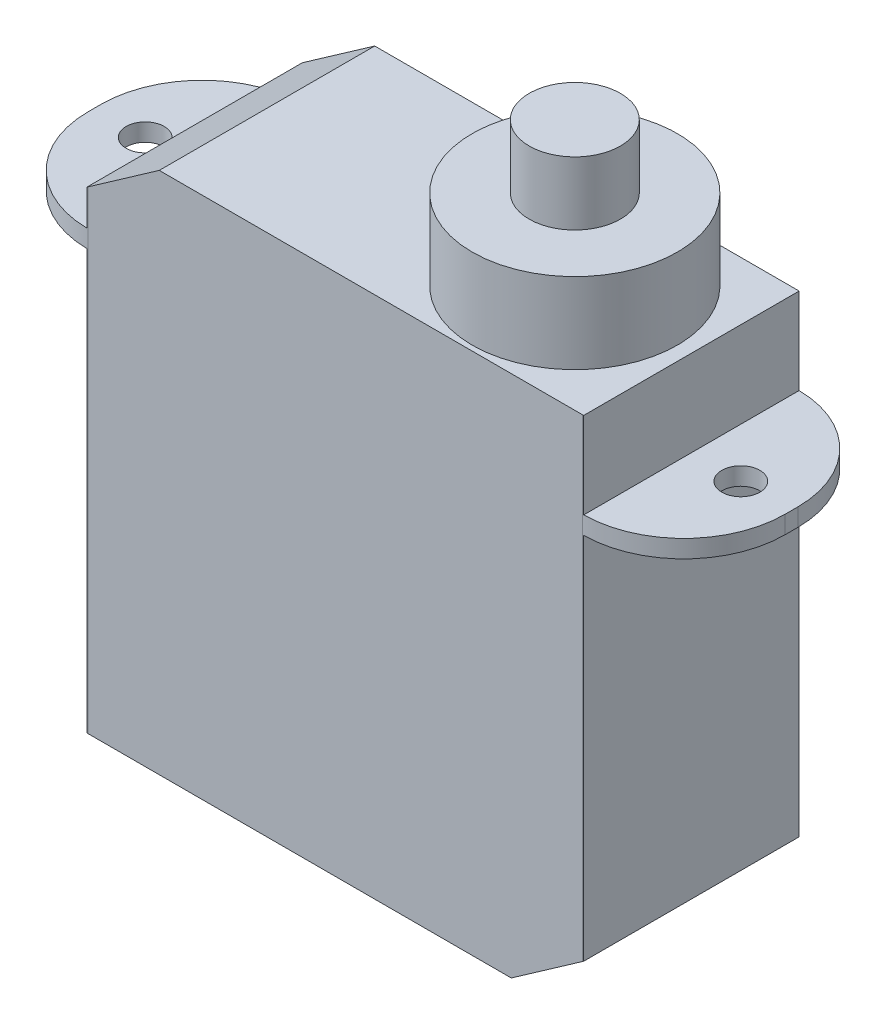
from build123d import *

# Parameters (mm, degrees)
SKETCH1_W                = 19.6
SKETCH1_H                = 8.5
BOSS_EXTRUDE1_DEPTH      = 3.4
BOSS_EXTRUDE1_DEPTH_BACK = 17.25
SKETCH2_R                = 4.05
BOSS_EXTRUDE2_DEPTH      = 3.18
SKETCH4_W                = 3.95
SKETCH4_H                = 8.5
SKETCH4_R                = 0.75
BOSS_EXTRUDE3_DEPTH      = 0.7
FILLET1_R                = 4
SKETCH5_R                = 1.8
BOSS_EXTRUDE4_DEPTH      = 2.5
CHAMFER1_SIZE            = 2
CHAMFER1_SIZE2           = 2.856296013
CHAMFER1_PART_2_SIZE     = 2
CHAMFER1_PART_2_SIZE2    = 2.856296013


with BuildPart() as part:
    # Sketch1 → Boss-Extrude1 (new body, two sides)
    with BuildSketch(Plane(origin=(0, 0, 0), x_dir=(1, 0, 0), z_dir=(0, 1, 0))) as boss_extrude1_sk:
        Rectangle(SKETCH1_W, SKETCH1_H)
    extrude(amount=BOSS_EXTRUDE1_DEPTH)
    extrude(boss_extrude1_sk.sketch, amount=-BOSS_EXTRUDE1_DEPTH_BACK)

    # Sketch2 → Boss-Extrude2 (add)
    with BuildSketch(Plane(origin=(0, 3.4, 0), x_dir=(1, 0, 0), z_dir=(0, 1, 0))):
        with Locations((5.2, 0)):
            Circle(SKETCH2_R)
    extrude(amount=BOSS_EXTRUDE2_DEPTH)

    # Sketch4 → Boss-Extrude3 (add)
    with BuildSketch(Plane(origin=(0, 0, 0), x_dir=(1, 0, 0), z_dir=(0, 1, 0))):
        with Locations((11.775, 0)):
            Rectangle(SKETCH4_W, SKETCH4_H)
        with Locations((11.75, 0)):
            Circle(SKETCH4_R, mode=Mode.SUBTRACT)
        with Locations((-11.775, 0)):
            Rectangle(SKETCH4_W, SKETCH4_H)
        with Locations((-11.75, 0)):
            Circle(SKETCH4_R, mode=Mode.SUBTRACT)
    extrude(amount=-BOSS_EXTRUDE3_DEPTH)

    # Fillet1
    fillet1_edges = [part.edges().sort_by_distance(p)[0] for p in [
        (13.75, -0.35, -4.25),
        (13.75, -0.35, 4.25),
        (-13.75, -0.35, -4.25),
        (-13.75, -0.35, 4.25),
    ]]
    fillet(fillet1_edges, radius=FILLET1_R)

    # Sketch5 → Boss-Extrude4 (add)
    with BuildSketch(Plane(origin=(0, 6.58, 0), x_dir=(1, 0, 0), z_dir=(0, 1, 0))):
        with Locations((5.2, 0)):
            Circle(SKETCH5_R)
    extrude(amount=BOSS_EXTRUDE4_DEPTH)

    # Chamfer1
    chamfer1_edges = [part.edges().sort_by_distance(p)[0] for p in [
        (9.8, -17.25, 0),
    ]]
    chamfer1_side = [part.faces().sort_by_distance(p)[0] for p in [
        (9.8, -8.975, 0),
    ]]
    chamfer(chamfer1_edges, length=CHAMFER1_SIZE, length2=CHAMFER1_SIZE2, reference=chamfer1_side[0])

    # Chamfer1 part 2
    chamfer1_part_2_edges = [part.edges().sort_by_distance(p)[0] for p in [
        (-9.8, 3.4, 0),
    ]]
    chamfer1_part_2_side = [part.faces().sort_by_distance(p)[0] for p in [
        (-9.8, 1.7, 0),
    ]]
    chamfer(chamfer1_part_2_edges, length=CHAMFER1_PART_2_SIZE, length2=CHAMFER1_PART_2_SIZE2, reference=chamfer1_part_2_side[0])


solid = part.part
